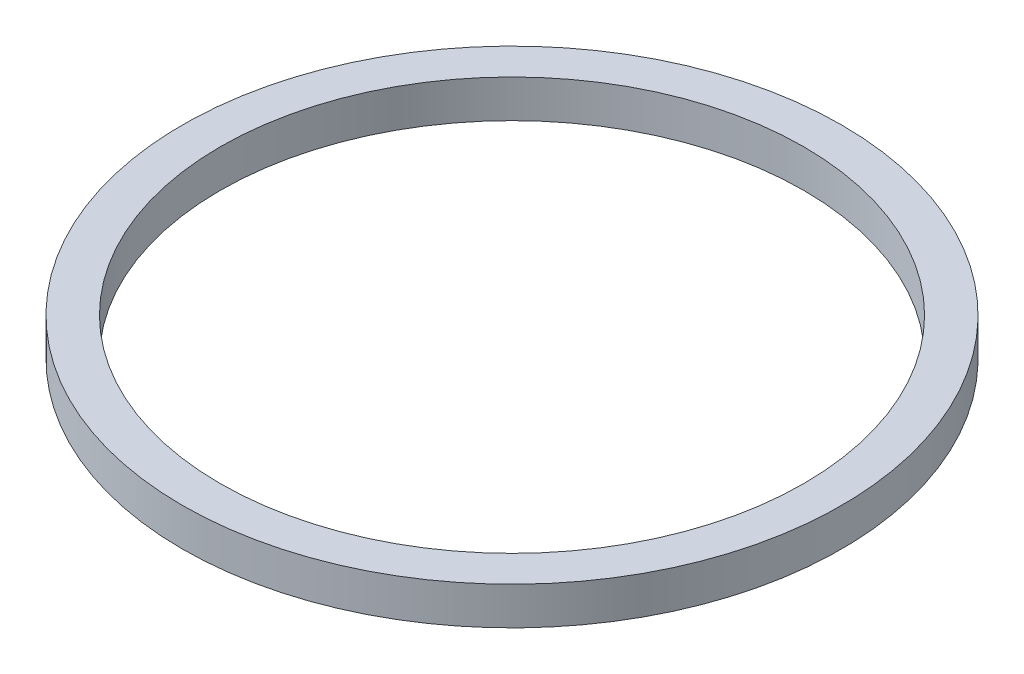
from build123d import *

# Parameters (mm, degrees)
SKETCH_1_W = 14
SKETCH_1_H = 14


with BuildPart() as part:
    # 草图1 → 旋转1 (revolve)
    with BuildSketch(Plane.XY):
        with Locations((115, 0)):
            Rectangle(SKETCH_1_W, SKETCH_1_H)
    revolve(axis=Axis((0, 0, 0), (0, 1, 0)))


solid = part.part
